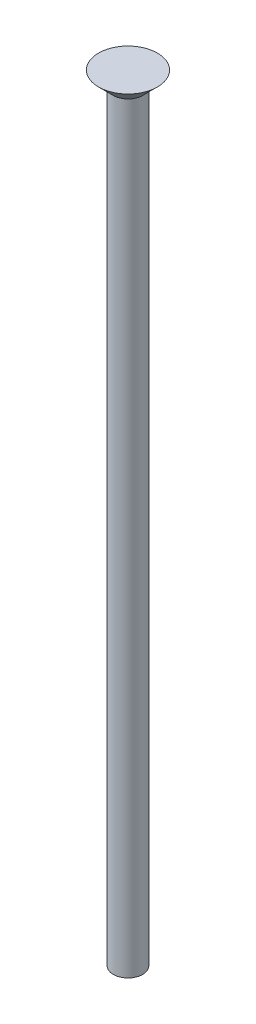
from build123d import *

# Parameters (mm, degrees)
SKETCH1_R           = 1.6
BOSS_EXTRUDE1_DEPTH = 84.4


with BuildPart() as part:
    # Sketch1 → Boss-Extrude1 (new body)
    with BuildSketch(Plane(origin=(0, 0, 0), x_dir=(1, 0, 0), z_dir=(0, 1, 0))):
        Circle(SKETCH1_R)
    extrude(amount=BOSS_EXTRUDE1_DEPTH)

    # Sketch4 → Revolve1 (revolve)
    with BuildSketch(Plane.XY):
        Polygon((1.6, 84.4), (1.6, 82.80001564), (3.199963324, 84.4), align=None)
    revolve(axis=Axis((0, 84.4, 0), (0, -1, 0)))


solid = part.part
